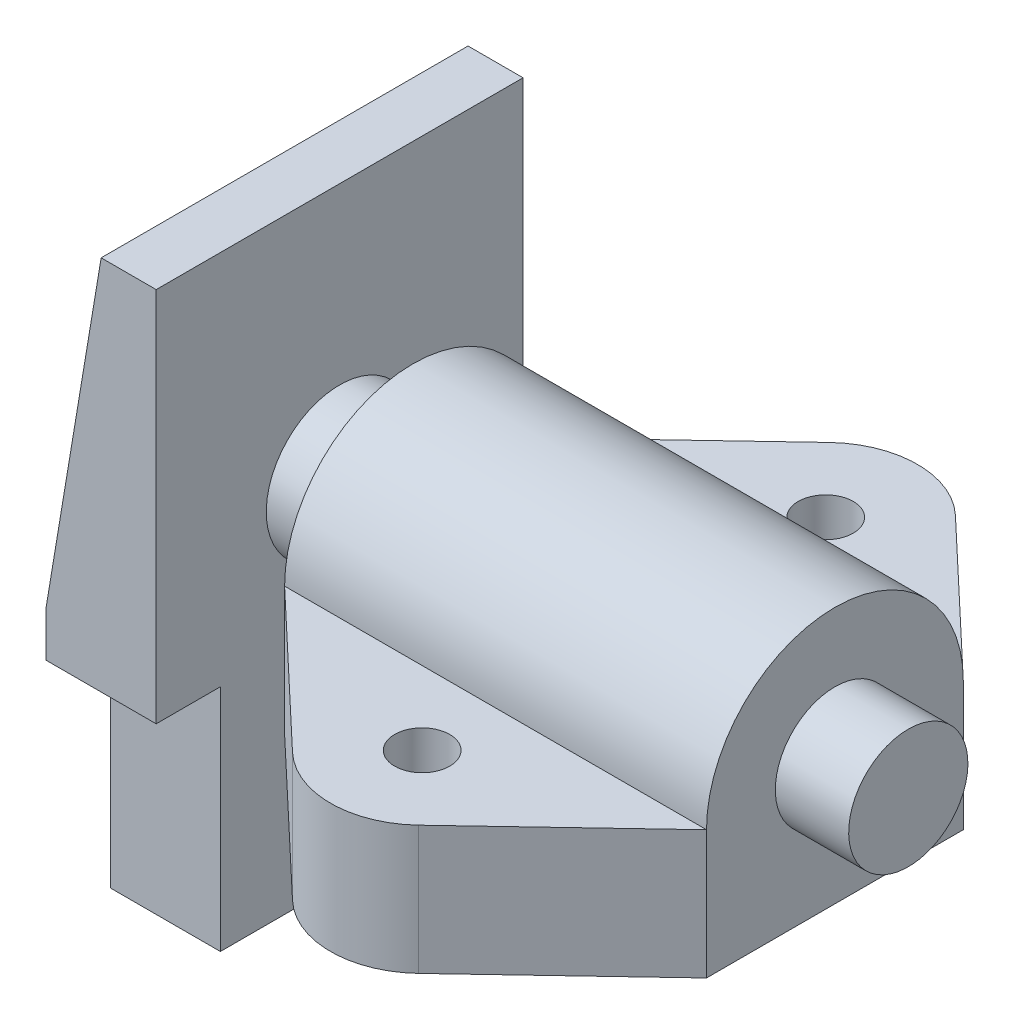
from build123d import *

# Parameters (mm, degrees)
ESTRUSIONE_ESTRUSIONE1_DEPTH = 20
SCHIZZO2_W                   = 12
SCHIZZO2_H                   = 25
TAGLIO_ESTRUSIONE1_DEPTH     = 7
SCHIZZO3_R                   = 8
ESTRUSIONE_ESTRUSIONE2_DEPTH = 8
ESTRUSIONE_ESTRUSIONE3_DEPTH = 46
ESTRUSIONE_ESTRUSIONE5_DEPTH = 14
SCHIZZO6_R                   = 6.5
ESTRUSIONE_ESTRUSIONE6_DEPTH = 8
SCHIZZO7_R                   = 3
TAGLIO_ESTRUSIONE2_DEPTH     = 40


with BuildPart() as part:
    # Schizzo1 → Estrusione-Estrusione1 (new body, symmetric)
    with BuildSketch(Plane.XY):
        Polygon((0, 33), (6, 33), (6, -33), (-6, -33), (-6, -3), align=None)
    extrude(amount=ESTRUSIONE_ESTRUSIONE1_DEPTH, both=True)

    # Schizzo2 → Taglio-Estrusione1 (cut)
    with BuildSketch(Plane.XY.offset(20)):
        with Locations((0, -20.5)):
            Rectangle(SCHIZZO2_W, SCHIZZO2_H)
    taglio_estrusione1 = extrude(amount=-TAGLIO_ESTRUSIONE1_DEPTH, mode=Mode.SUBTRACT)

    # Specchia1: Taglio-Estrusione1 across plane
    add(taglio_estrusione1.mirror(Plane.XY), mode=Mode.SUBTRACT)

    # Schizzo3 → Estrusione-Estrusione2 (add)
    with BuildSketch(Plane(origin=(6, 0, 0), x_dir=(0, 0, -1), z_dir=(1, 0, 0))):
        with Locations((0, 6)):
            Circle(SCHIZZO3_R)
    extrude(amount=ESTRUSIONE_ESTRUSIONE2_DEPTH)

    # Schizzo4 → Estrusione-Estrusione3 (add)
    with BuildSketch(Plane(origin=(14, 0, 0), x_dir=(0, 0, -1), z_dir=(1, 0, 0))):
        with BuildLine():
            Line((-14, 6), (-14, -8))
            Line((-14, -8), (14, -8))
            Line((14, -8), (14, 6))
            ThreePointArc((14, 6), (0, 20), (-14, 6))
        make_face()
    extrude(amount=ESTRUSIONE_ESTRUSIONE3_DEPTH)

    # Schizzo5 → Estrusione-Estrusione5 (add)
    with BuildSketch(Plane(origin=(0, 6, 0), x_dir=(1, 0, 0), z_dir=(0, 1, 0))):
        with BuildLine():
            Line((14, -14), (60, -14))
            Line((60, -14), (43.874010565, -29.262780374))
            ThreePointArc((43.874010565, -29.262780374), (37, -32), (30.125989435, -29.262780374))
            Line((30.125989435, -29.262780374), (14, -14))
        make_face()
    estrusione_estrusione5 = extrude(amount=-ESTRUSIONE_ESTRUSIONE5_DEPTH)

    # Specchia2: Estrusione-Estrusione5 across plane
    add(estrusione_estrusione5.mirror(Plane.XY))

    # Schizzo6 → Estrusione-Estrusione6 (add)
    with BuildSketch(Plane(origin=(60, 0, 0), x_dir=(0, 0, -1), z_dir=(1, 0, 0))):
        with Locations((0, 6)):
            Circle(SCHIZZO6_R)
    extrude(amount=ESTRUSIONE_ESTRUSIONE6_DEPTH)

    # Schizzo7 → Taglio-Estrusione2 (cut, through all)
    with BuildSketch(Plane(origin=(0, 6, 0), x_dir=(1, 0, 0), z_dir=(0, 1, 0))):
        with Locations((37, -22)):
            Circle(SCHIZZO7_R)
    taglio_estrusione2 = extrude(amount=-TAGLIO_ESTRUSIONE2_DEPTH, mode=Mode.SUBTRACT)

    # Specchia3: Taglio-Estrusione2 across plane
    add(taglio_estrusione2.mirror(Plane.XY), mode=Mode.SUBTRACT)


solid = part.part
